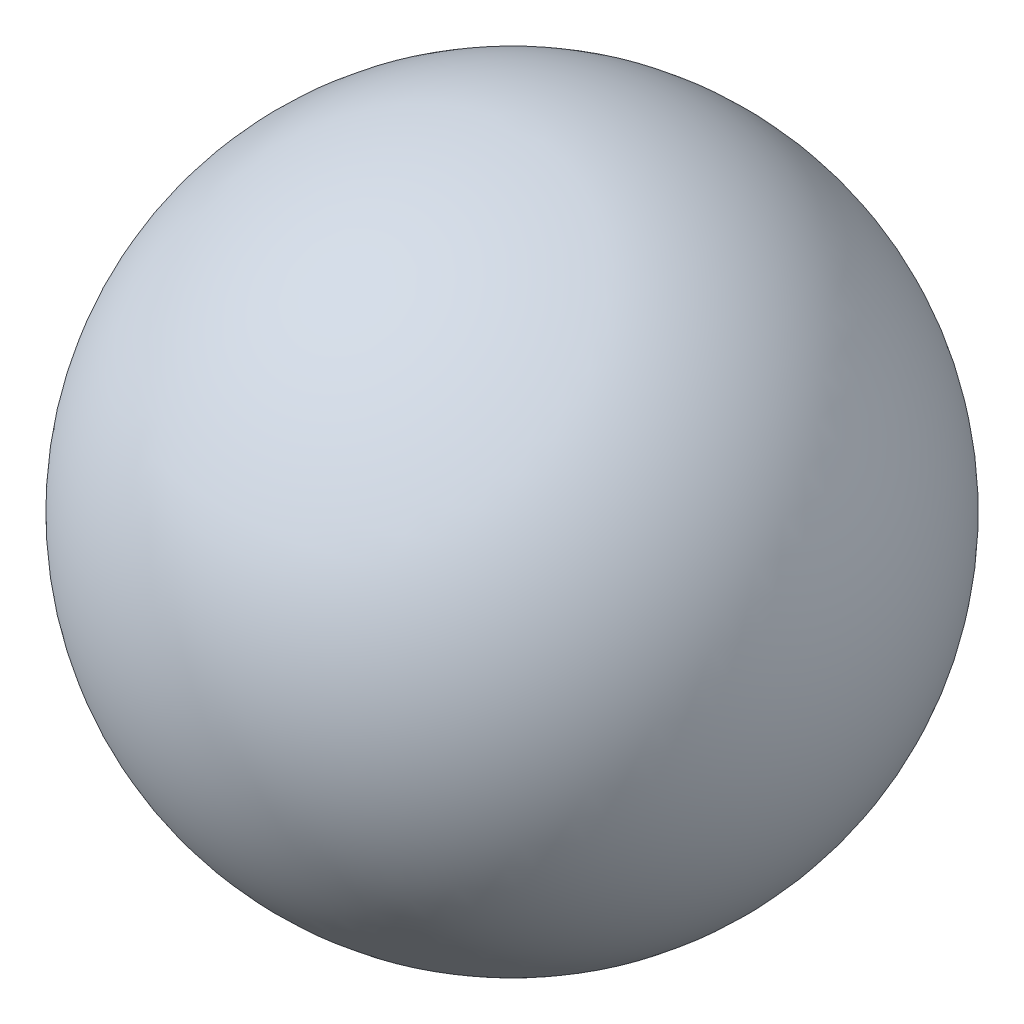
from build123d import *


with BuildPart() as part:
    # Sketch1 → Revolve1 (revolve)
    with BuildSketch(Plane.XY):
        with BuildLine():
            Line((0, 34.1), (0, 36.5))
            ThreePointArc((0, 36.5), (36.5, 0), (0, -36.5))
            Line((0, -36.5), (0, -34.1))
            ThreePointArc((0, -34.1), (34.1, 0), (0, 34.1))
        make_face()
    revolve(axis=Axis((0, 34.1, 0), (0, -1, 0)))


solid = part.part
